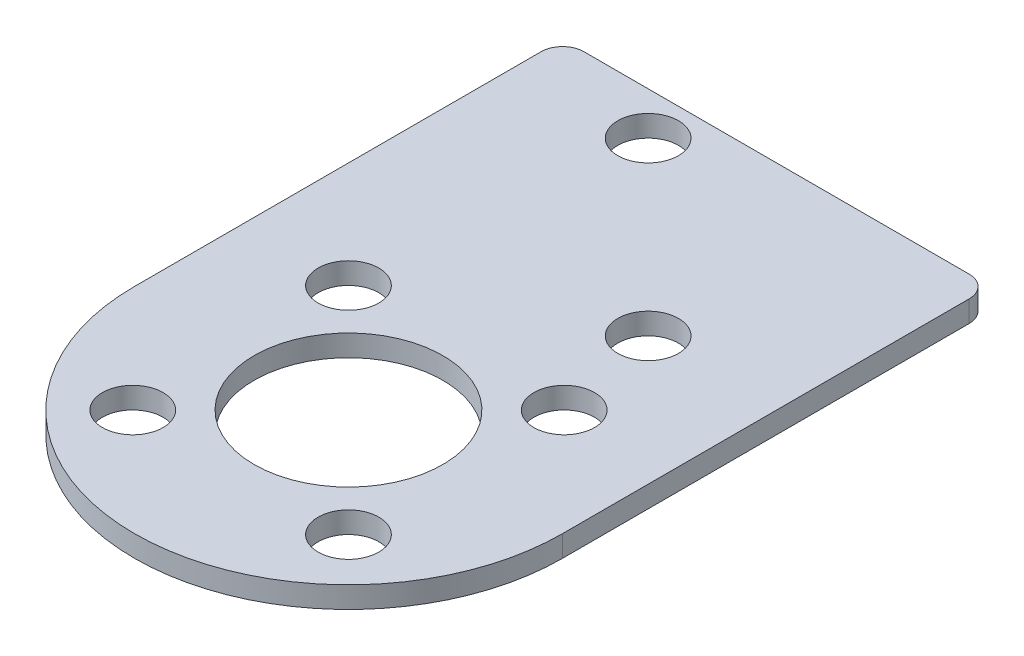
from build123d import *

# Parameters (mm, degrees)
SKETCH1_R           = 7
SKETCH1_R_2         = 2.25
BOSS_EXTRUDE1_DEPTH = 1.5875


with BuildPart() as part:
    # Sketch1 → Boss-Extrude1 (new body)
    with BuildSketch(Plane(origin=(0, 0, 0), x_dir=(1, 0, 0), z_dir=(0, 1, 0))):
        with BuildLine():
            Line((-15.875, 0), (-15.875, 30.1625))
            ThreePointArc((-15.875, 30.1625), (-15.410032015, 31.285032015), (-14.2875, 31.75))
            Line((-14.2875, 31.75), (14.2875, 31.75))
            ThreePointArc((14.2875, 31.75), (15.410032015, 31.285032015), (15.875, 30.1625))
            Line((15.875, 30.1625), (15.875, 0))
            ThreePointArc((15.875, 0), (0, -15.875), (-15.875, 0))
        make_face()
        Circle(SKETCH1_R, mode=Mode.SUBTRACT)
        with Locations((-8, 8)):
            Circle(SKETCH1_R_2, mode=Mode.SUBTRACT)
        with Locations((8, 8)):
            Circle(SKETCH1_R_2, mode=Mode.SUBTRACT)
        with Locations((8, -8)):
            Circle(SKETCH1_R_2, mode=Mode.SUBTRACT)
        with Locations((-8, -8)):
            Circle(SKETCH1_R_2, mode=Mode.SUBTRACT)
        with Locations((-6.35, 28.575)):
            Circle(SKETCH1_R_2, mode=Mode.SUBTRACT)
        with Locations((6.35, 15.875)):
            Circle(SKETCH1_R_2, mode=Mode.SUBTRACT)
    extrude(amount=BOSS_EXTRUDE1_DEPTH)


solid = part.part
